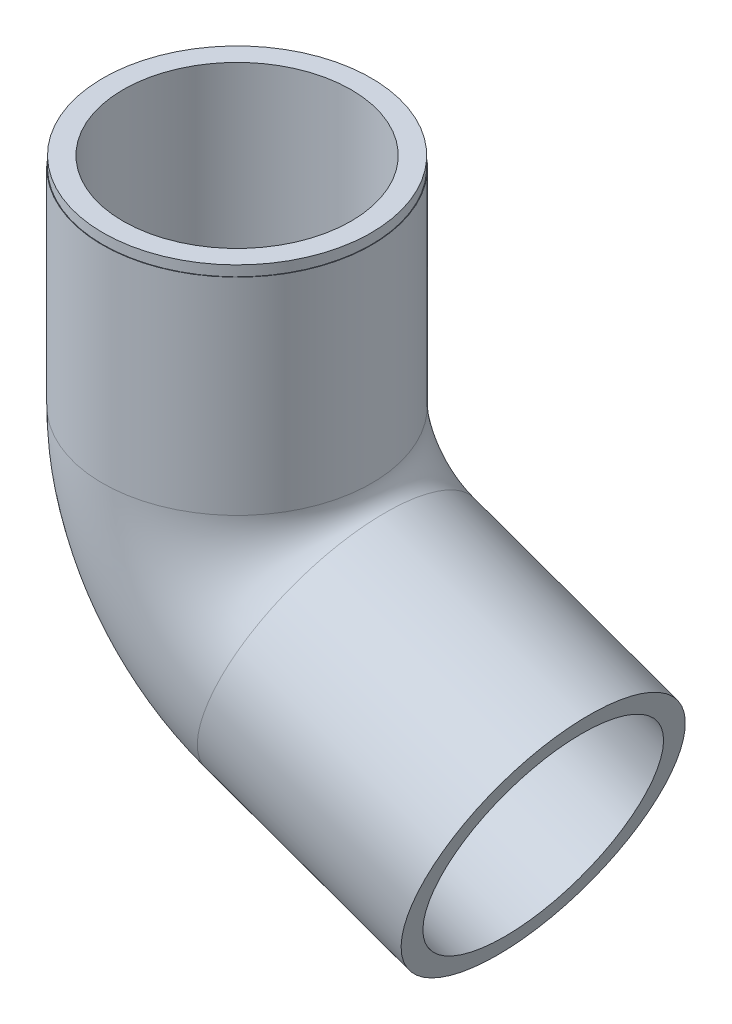
from build123d import *

# Parameters (mm, degrees)
CROQUIS1_R                 = 13
CROQUIS1_R_2               = 11.05
SALIENTE_EXTRUIR1_DEPTH    = 1
BARRER_L_MINA1_PROFILE_R   = 13.05
BARRER_L_MINA1_PROFILE_R_2 = 11.05


with BuildPart() as part:
    # Croquis1 → Saliente-Extruir1 (new body)
    with BuildSketch(Plane(origin=(0, 0, 0), x_dir=(1, 0, 0), z_dir=(0, 1, 0))):
        with Locations(Location((0, 0, 0), (0, 0, 270))):
            Circle(CROQUIS1_R)
        with Locations(Location((0, 0, 0), (0, 0, 270))):
            Circle(CROQUIS1_R_2, mode=Mode.SUBTRACT)
    extrude(amount=-SALIENTE_EXTRUIR1_DEPTH)

    # Barrer-L_mina1: sweep along a path in Croquis2
    with BuildLine(Plane.XY) as barrer_l_mina1_path:
        Line((0, -1), (0, -21))
        ThreePointArc((0, -21), (2.727754239, -29.625078781), (9.918931196, -35.113211534))
        Line((9.918931196, -35.113211534), (29.677427344, -42.226707859))
    # Barrer-L_mina1 profile (on start of the path) → Barrer-L_mina1 (sweep)
    with BuildSketch(Plane(origin=(0, -1, 0), x_dir=(-1, 0, 0), z_dir=(0, -1, 0))):
        Circle(BARRER_L_MINA1_PROFILE_R)
        Circle(BARRER_L_MINA1_PROFILE_R_2, mode=Mode.SUBTRACT)
    sweep(path=barrer_l_mina1_path.line)


solid = part.part
